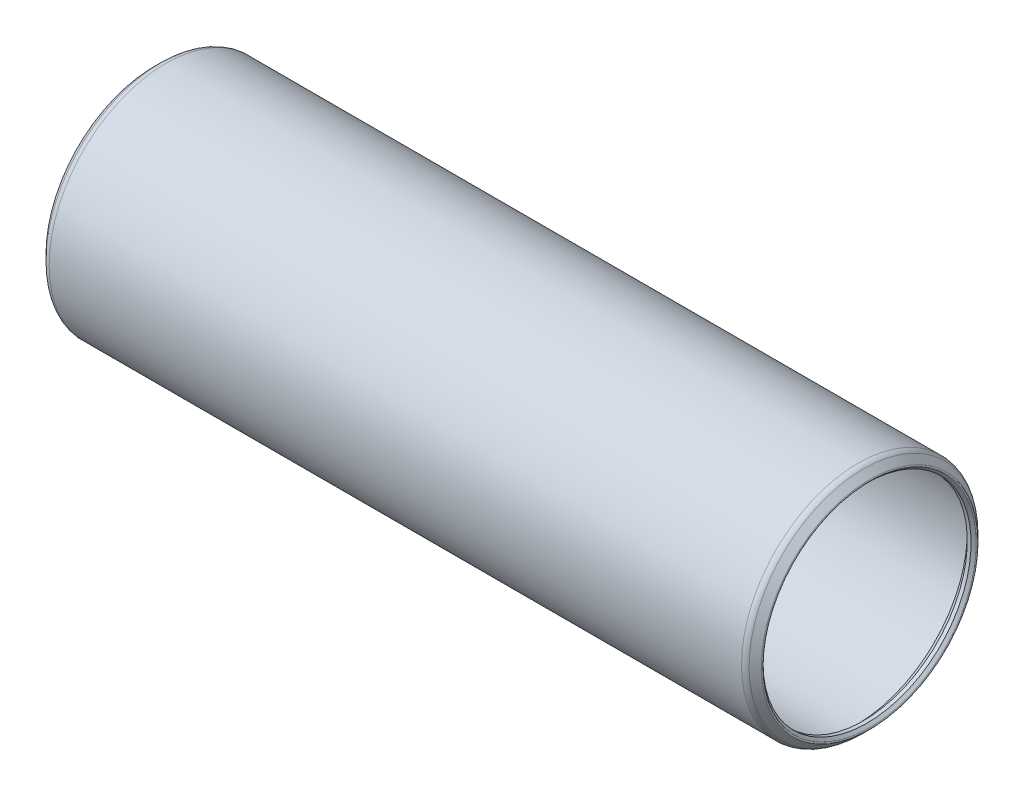
from build123d import *


with BuildPart() as part:
    # Sketch1 → Revolve1 (revolve)
    with BuildSketch(Plane.XY):
        with BuildLine():
            Line((-0.639512806, 10.742362806), (-0.381, 10.48385))
            Line((-0.381, 10.48385), (0, 10.48385))
            Line((0, 10.48385), (0.762, 11.24585))
            Line((0.762, 11.24585), (70.0532, 11.24585))
            Line((70.0532, 11.24585), (70.8152, 10.48385))
            Line((70.8152, 10.48385), (71.1962, 10.48385))
            Line((71.1962, 10.48385), (71.454712806, 10.742362806))
            ThreePointArc((71.454712806, 10.742362806), (71.491910245, 10.832165367), (71.454712806, 10.921967928))
            Line((71.454712806, 10.921967928), (70.839665367, 11.537015367))
            ThreePointArc((70.839665367, 11.537015367), (70.592454775, 11.702196204), (70.30085, 11.7602))
            Line((70.30085, 11.7602), (0.51435, 11.7602))
            ThreePointArc((0.51435, 11.7602), (0.222745225, 11.702196204), (-0.024465367, 11.537015367))
            Line((-0.024465367, 11.537015367), (-0.639512806, 10.921967928))
            ThreePointArc((-0.639512806, 10.921967928), (-0.676710245, 10.832165367), (-0.639512806, 10.742362806))
        make_face()
    revolve(axis=Axis((70.8152, 0, 0), (-1, 0, 0)))


solid = part.part
